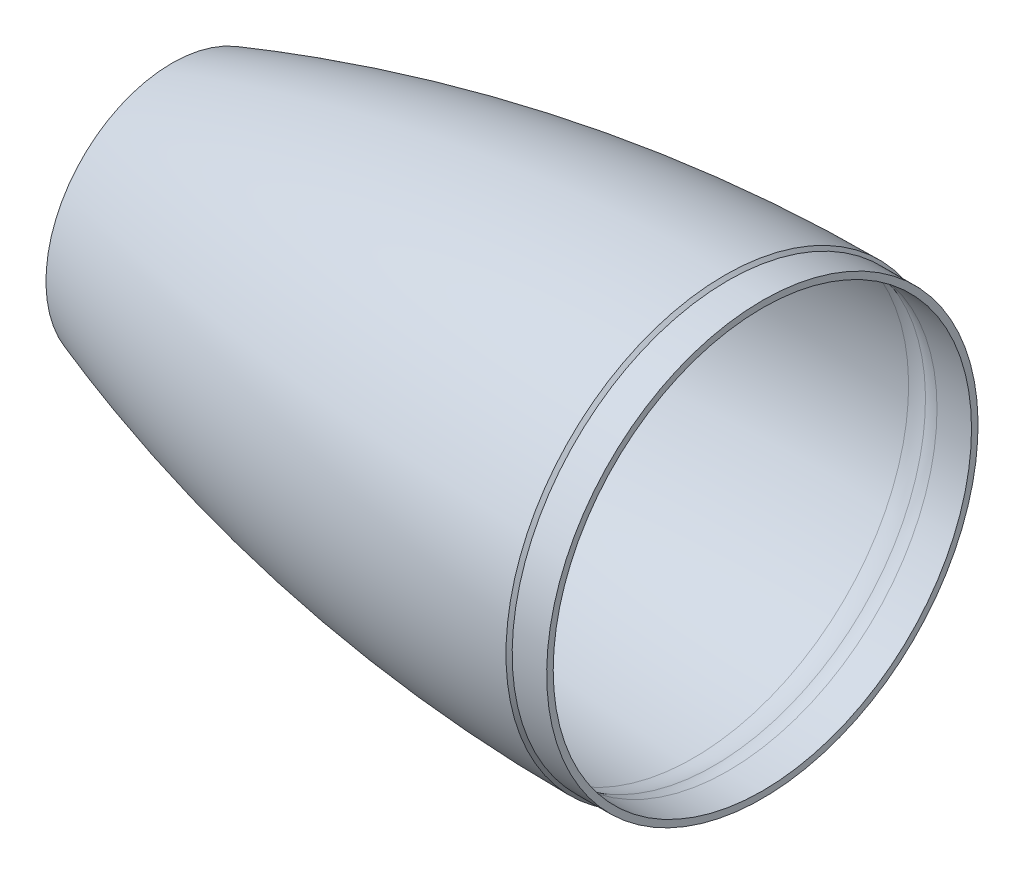
from build123d import *


with BuildPart() as part:
    # Sketch1 → Revolve1 (revolve)
    with BuildSketch(Plane.XY):
        with BuildLine():
            Line((-203.454, 46.355), (-203.454, 45.085221158))
            ThreePointArc((-203.454, 45.085221158), (-108.851125127, 69.714747297), (-11.557, 79.210573098))
            ThreePointArc((-11.557, 79.210573098), (-7.739504947, 78.920164754), (-4.044584679, 77.917583239))
            ThreePointArc((-4.044584679, 77.917583239), (-1.493261461, 77.212559303), (1.143, 76.975))
            Line((1.143, 76.975), (13.843, 76.975))
            Line((13.843, 76.975), (13.843, 79.375))
            Line((13.843, 79.375), (1.143, 79.375))
            Line((1.143, 79.375), (0, 80.518))
            ThreePointArc((0, 80.518), (-103.15115206, 71.917881411), (-203.454, 46.355))
        make_face()
    revolve(axis=Axis((0, 0, 0), (-1, 0, 0)))


solid = part.part
